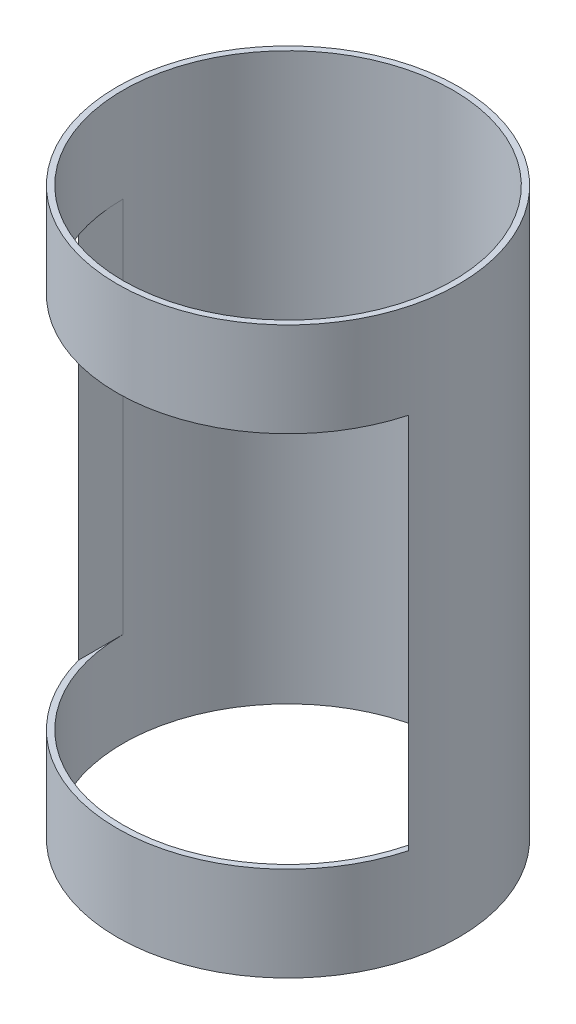
from build123d import *

# Parameters (mm, degrees)
SKETCH1_R           = 92.075
SKETCH1_R_2         = 88.9
BOSS_EXTRUDE1_DEPTH = 304.8
SKETCH2_W           = 177.8
SKETCH2_H           = 203.2
CUT_EXTRUDE1_DEPTH  = 93.075


with BuildPart() as part:
    # Sketch1 → Boss-Extrude1 (new body)
    with BuildSketch(Plane(origin=(0, 0, 0), x_dir=(1, 0, 0), z_dir=(0, 1, 0))):
        Circle(SKETCH1_R)
        Circle(SKETCH1_R_2, mode=Mode.SUBTRACT)
    extrude(amount=BOSS_EXTRUDE1_DEPTH)

    # Sketch2 → Cut-Extrude1 (cut, through all)
    with BuildSketch(Plane.XY):
        with Locations((0, 152.4)):
            Rectangle(SKETCH2_W, SKETCH2_H)
    extrude(amount=CUT_EXTRUDE1_DEPTH, mode=Mode.SUBTRACT)


solid = part.part
